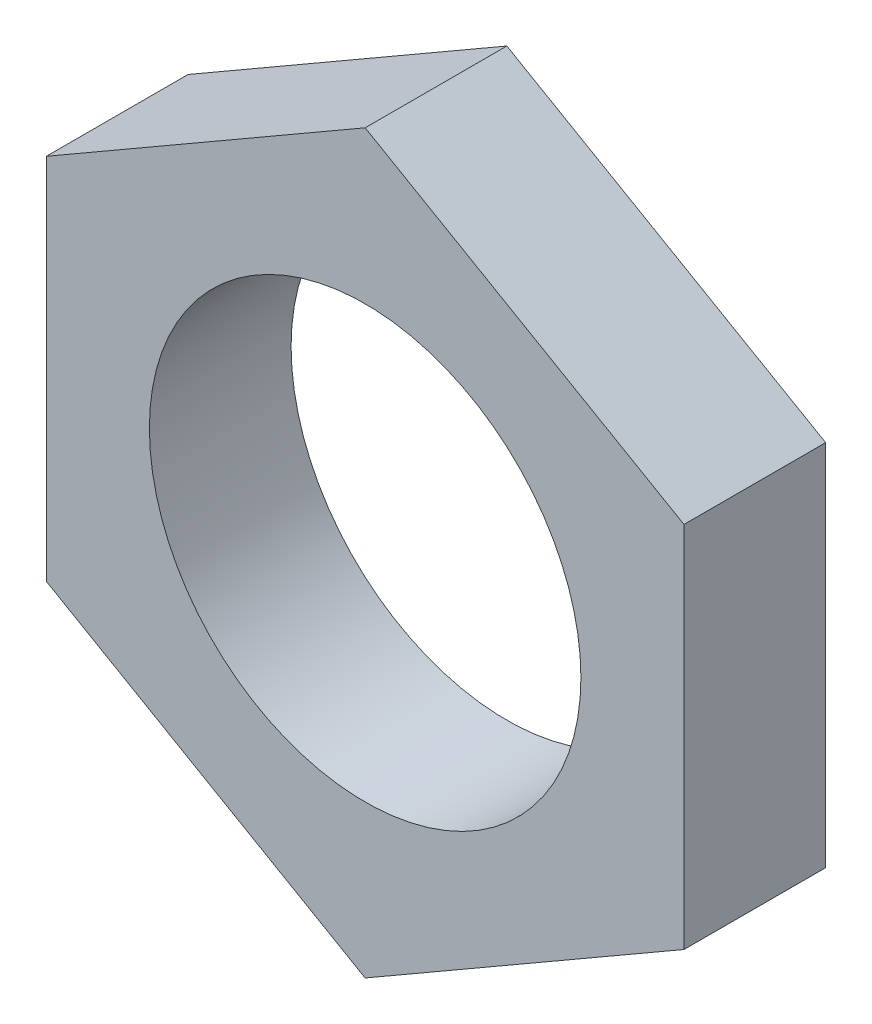
from build123d import *

# Parameters (mm, degrees)
SKETCH1_R           = 3.35
BOSS_EXTRUDE1_DEPTH = 2.2


with BuildPart() as part:
    # Sketch1 → Boss-Extrude1 (new body)
    with BuildSketch(Plane.XY):
        Polygon((4.95, 2.857883832), (0, 5.715767665), (-4.95, 2.857883832), (-4.95, -2.857883832), (0, -5.715767665), (4.95, -2.857883832), align=None)
        Circle(SKETCH1_R, mode=Mode.SUBTRACT)
    extrude(amount=BOSS_EXTRUDE1_DEPTH)


solid = part.part
